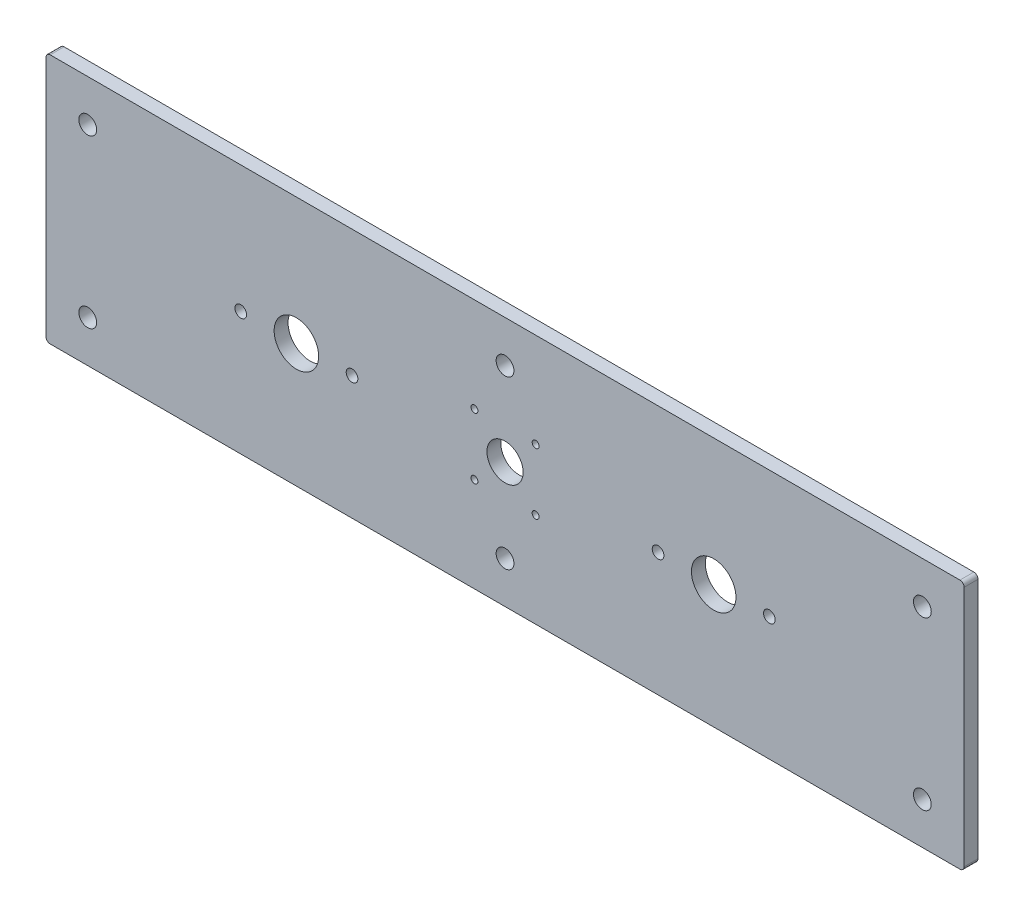
from build123d import *

# Parameters (mm, degrees)
SKETCH1_W                = 330
SKETCH1_H                = 90
BOSS_EXTRUDE1_DEPTH      = 2.5
M6_CLEARANCE_HOLE1_D     = 6.4
M6_CLEARANCE_HOLE1_DEPTH = 10
M6_CLEARANCE_HOLE1_TIP   = 1.922753981
SKETCH3_R                = 8
CUT_EXTRUDE2_DEPTH       = 6
M5X0_8_TAPPED_HOLE1_D    = 4.2
SKETCH4_R                = 6.5
CUT_EXTRUDE3_DEPTH       = 6
M3X0_5_TAPPED_HOLE1_D    = 2.5
FILLET1_R                = 1.5


with BuildPart() as part:
    # Sketch1 → Boss-Extrude1 (new body, symmetric)
    with BuildSketch(Plane.XY):
        Rectangle(SKETCH1_W, SKETCH1_H)
    extrude(amount=BOSS_EXTRUDE1_DEPTH, both=True)

    # M6 Clearance Hole1
    with Locations(Plane.XY.offset(2.5)):
        with Locations((-150, 30), (-150, -30), (0, 30), (0, -30), (150, -30), (150, 30)):
            Hole(M6_CLEARANCE_HOLE1_D / 2, depth=M6_CLEARANCE_HOLE1_DEPTH)
            with Locations((0, 0, -(M6_CLEARANCE_HOLE1_DEPTH + M6_CLEARANCE_HOLE1_TIP / 2))):  # 118° drill point
                Cone(0, M6_CLEARANCE_HOLE1_D / 2, M6_CLEARANCE_HOLE1_TIP, mode=Mode.SUBTRACT)

    # Sketch3 → Cut-Extrude2 (cut, through all)
    with BuildSketch(Plane.XY.offset(2.5)):
        with Locations((-75, -0.6)):
            Circle(SKETCH3_R)
    cut_extrude2 = extrude(amount=-CUT_EXTRUDE2_DEPTH, mode=Mode.SUBTRACT)

    # M5x0.8 Tapped Hole1 (through all)
    with Locations(Plane.XY.offset(2.5)):
        with Locations((-95, -0.6), (-55, -0.6)):
            m5x0_8_tapped_hole1 = Hole(M5X0_8_TAPPED_HOLE1_D / 2)

    # Mirror1: Cut-Extrude2, M5x0.8 Tapped Hole1 across plane
    add(cut_extrude2.mirror(Plane(origin=(0, 0, 0), x_dir=(0, 0, 1), z_dir=(1, 0, 0))), mode=Mode.SUBTRACT)
    add(m5x0_8_tapped_hole1.mirror(Plane(origin=(0, 0, 0), x_dir=(0, 0, 1), z_dir=(1, 0, 0))), mode=Mode.SUBTRACT)

    # Sketch4 → Cut-Extrude3 (cut, through all)
    with BuildSketch(Plane.XY.offset(2.5)):
        Circle(SKETCH4_R)
    extrude(amount=-CUT_EXTRUDE3_DEPTH, mode=Mode.SUBTRACT)

    # M3x0.5 Tapped Hole1 (through all)
    with Locations(Plane.XY.offset(2.5)):
        with Locations((11, 11), (-11, -11), (-11, 11), (11, -11)):
            Hole(M3X0_5_TAPPED_HOLE1_D / 2)

    # Fillet1
    fillet1_edges = [part.edges().sort_by_distance(p)[0] for p in [
        (165, -45, 0),
        (-165, -45, 0),
        (-165, 45, 0),
        (165, 45, 0),
    ]]
    fillet(fillet1_edges, radius=FILLET1_R)


solid = part.part
